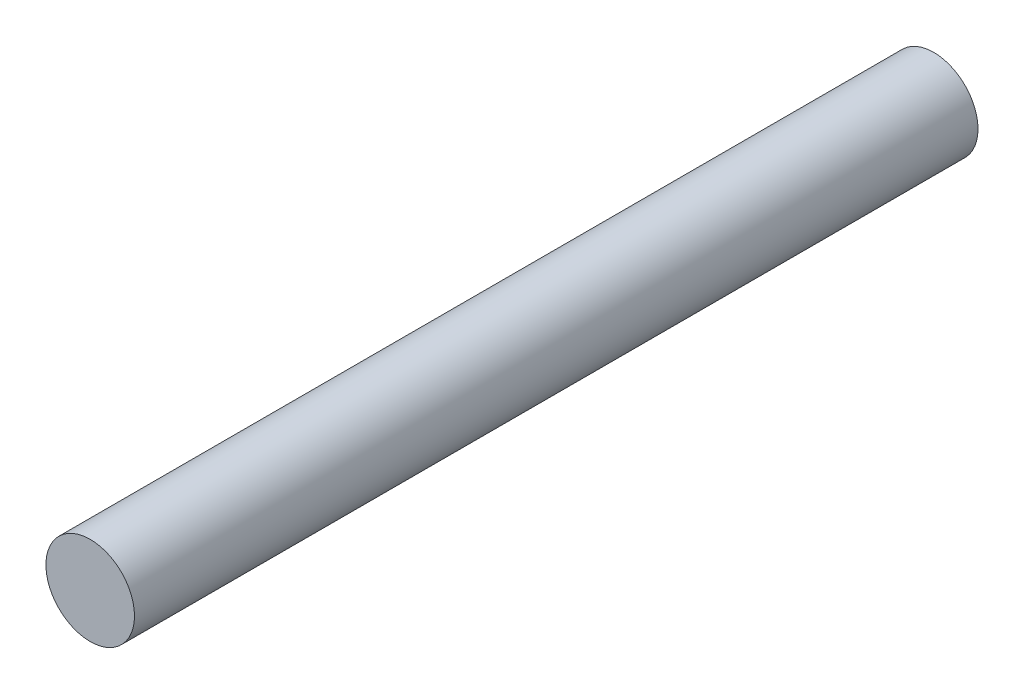
from build123d import *

# Parameters (mm, degrees)
SKETCH1_R           = 1.05
BOSS_EXTRUDE1_DEPTH = 20


with BuildPart() as part:
    # Sketch1 → Boss-Extrude1 (new body)
    with BuildSketch(Plane.XY):
        Circle(SKETCH1_R)
    extrude(amount=BOSS_EXTRUDE1_DEPTH)


solid = part.part
